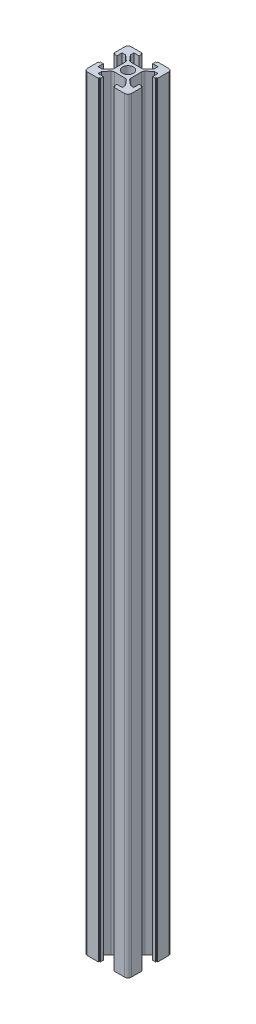
from build123d import *

# Parameters (mm, degrees)
SKETCH1_R           = 2.5
BOSS_EXTRUDE1_DEPTH = 350


with BuildPart() as part:
    # Sketch1 → Boss-Extrude1 (new body)
    with BuildSketch(Plane(origin=(0, 0, 0), x_dir=(1, 0, 0), z_dir=(0, 1, 0))):
        with BuildLine():
            ThreePointArc((-10, -8.5), (-9.560660172, -9.560660172), (-8.5, -10))
            Line((-8.5, -10), (-3.6, -10))
            Line((-3.6, -10), (-3.6, -9.5))
            Line((-3.6, -9.5), (-3.1, -9.5))
            Line((-3.1, -9.5), (-3.1, -8.2))
            Line((-3.1, -8.2), (-5.5, -8.2))
            Line((-5.5, -8.2), (-5.5, -6.6))
            Line((-5.5, -6.6), (-3.54898252, -4.32381294))
            ThreePointArc((-3.54898252, -4.32381294), (-3.036882831, -3.937230652), (-2.410097616, -3.8))
            Line((-2.410097616, -3.8), (2.410097616, -3.8))
            ThreePointArc((2.410097616, -3.8), (3.036882831, -3.937230652), (3.54898252, -4.32381294))
            Line((3.54898252, -4.32381294), (5.5, -6.6))
            Line((5.5, -6.6), (5.5, -8.2))
            Line((5.5, -8.2), (3.1, -8.2))
            Line((3.1, -8.2), (3.1, -9.5))
            Line((3.1, -9.5), (3.6, -9.5))
            Line((3.6, -9.5), (3.6, -10))
            Line((3.6, -10), (8.5, -10))
            ThreePointArc((8.5, -10), (9.560660172, -9.560660172), (10, -8.5))
            Line((10, -8.5), (10, -3.6))
            Line((10, -3.6), (9.5, -3.6))
            Line((9.5, -3.6), (9.5, -3.1))
            Line((9.5, -3.1), (8.2, -3.1))
            Line((8.2, -3.1), (8.2, -5.5))
            Line((8.2, -5.5), (6.6, -5.5))
            Line((6.6, -5.5), (4.32381294, -3.54898252))
            ThreePointArc((4.32381294, -3.54898252), (3.937230652, -3.036882831), (3.8, -2.410097616))
            Line((3.8, -2.410097616), (3.8, 2.410097616))
            ThreePointArc((3.8, 2.410097616), (3.937230652, 3.036882831), (4.32381294, 3.54898252))
            Line((4.32381294, 3.54898252), (6.6, 5.5))
            Line((6.6, 5.5), (8.2, 5.5))
            Line((8.2, 5.5), (8.2, 3.1))
            Line((8.2, 3.1), (9.5, 3.1))
            Line((9.5, 3.1), (9.5, 3.6))
            Line((9.5, 3.6), (10, 3.6))
            Line((10, 3.6), (10, 8.5))
            ThreePointArc((10, 8.5), (9.560660172, 9.560660172), (8.5, 10))
            Line((8.5, 10), (3.6, 10))
            Line((3.6, 10), (3.6, 9.5))
            Line((3.6, 9.5), (3.1, 9.5))
            Line((3.1, 9.5), (3.1, 8.2))
            Line((3.1, 8.2), (5.5, 8.2))
            Line((5.5, 8.2), (5.5, 6.6))
            Line((5.5, 6.6), (3.54898252, 4.32381294))
            ThreePointArc((3.54898252, 4.32381294), (3.036882831, 3.937230652), (2.410097616, 3.8))
            Line((2.410097616, 3.8), (-2.410097616, 3.8))
            ThreePointArc((-2.410097616, 3.8), (-3.036882831, 3.937230652), (-3.54898252, 4.32381294))
            Line((-3.54898252, 4.32381294), (-5.5, 6.6))
            Line((-5.5, 6.6), (-5.5, 8.2))
            Line((-5.5, 8.2), (-3.1, 8.2))
            Line((-3.1, 8.2), (-3.1, 9.5))
            Line((-3.1, 9.5), (-3.6, 9.5))
            Line((-3.6, 9.5), (-3.6, 10))
            Line((-3.6, 10), (-8.5, 10))
            ThreePointArc((-8.5, 10), (-9.560660172, 9.560660172), (-10, 8.5))
            Line((-10, 8.5), (-10, 3.6))
            Line((-10, 3.6), (-9.5, 3.6))
            Line((-9.5, 3.6), (-9.5, 3.1))
            Line((-9.5, 3.1), (-8.2, 3.1))
            Line((-8.2, 3.1), (-8.2, 5.5))
            Line((-8.2, 5.5), (-6.6, 5.5))
            Line((-6.6, 5.5), (-4.32381294, 3.54898252))
            ThreePointArc((-4.32381294, 3.54898252), (-3.937230652, 3.036882831), (-3.8, 2.410097616))
            Line((-3.8, 2.410097616), (-3.8, -2.410097616))
            ThreePointArc((-3.8, -2.410097616), (-3.937230652, -3.036882831), (-4.32381294, -3.54898252))
            Line((-4.32381294, -3.54898252), (-6.6, -5.5))
            Line((-6.6, -5.5), (-8.2, -5.5))
            Line((-8.2, -5.5), (-8.2, -3.1))
            Line((-8.2, -3.1), (-9.5, -3.1))
            Line((-9.5, -3.1), (-9.5, -3.6))
            Line((-9.5, -3.6), (-10, -3.6))
            Line((-10, -3.6), (-10, -8.5))
        make_face()
        Circle(SKETCH1_R, mode=Mode.SUBTRACT)
    extrude(amount=BOSS_EXTRUDE1_DEPTH)


solid = part.part
